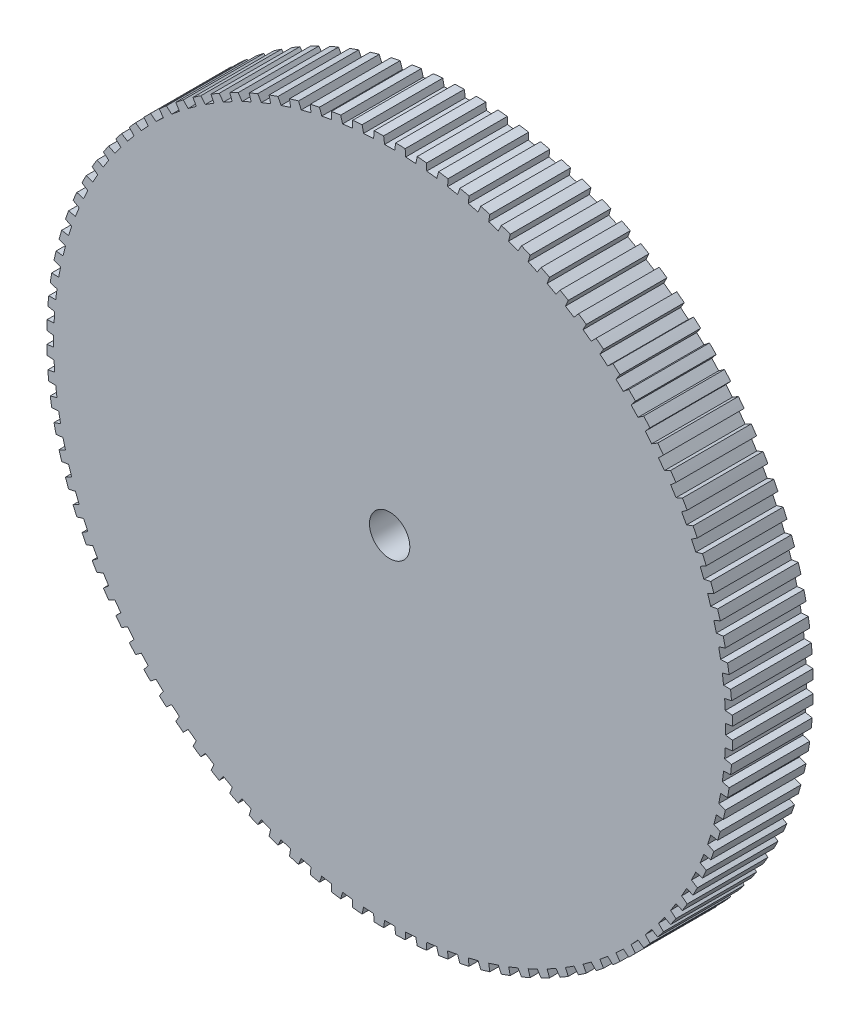
from build123d import *

# Parameters (mm, degrees)
SKETCH1_R                = 34
BOSS_EXTRUDE1_DEPTH      = 8
SKETCH4_R                = 4.85
BOSS_EXTRUDE2_DEPTH      = 8
SKETCH2_R                = 4
CUT_EXTRUDE1_DEPTH       = 4.35
SKETCH5_R                = 2
CUT_EXTRUDE2_DEPTH       = 4.15
CUT_EXTRUDE3_DEPTH       = 7.5
CUT_EXTRUDE4_DEPTH       = 17
CIRPATTERN1_COUNT        = 100
SKETCH8_R                = 4
SKETCH8_R_2              = 2
REVERSECOUNTERSINK_DEPTH = 4.35


with BuildPart() as part:
    # Sketch1 → Boss-Extrude1 (new body)
    with BuildSketch(Plane.XY):
        Circle(SKETCH1_R)
    extrude(amount=BOSS_EXTRUDE1_DEPTH)

    # Sketch4 → Boss-Extrude2 (add)
    with BuildSketch(Plane(origin=(0, 0, 0), x_dir=(-1, 0, 0), z_dir=(0, 0, -1))):
        Circle(SKETCH4_R)
    extrude(amount=BOSS_EXTRUDE2_DEPTH)

    # Sketch2 → Cut-Extrude1 (cut)
    with BuildSketch(Plane.XY.offset(8)):
        Circle(SKETCH2_R)
    extrude(amount=-CUT_EXTRUDE1_DEPTH, mode=Mode.SUBTRACT)

    # Sketch5 → Cut-Extrude2 (cut)
    with BuildSketch(Plane.XY.offset(3.65)):
        Circle(SKETCH5_R)
    extrude(amount=-CUT_EXTRUDE2_DEPTH, mode=Mode.SUBTRACT)

    # Sketch6 → Cut-Extrude3 (cut)
    with BuildSketch(Plane(origin=(0, 0, -8), x_dir=(-1, 0, 0), z_dir=(0, 0, -1))):
        with BuildLine():
            Line((2.078460969, 1.95), (-2.078460969, 1.95))
            ThreePointArc((-2.078460969, 1.95), (-2.85, 0), (-2.078460969, -1.95))
            Line((-2.078460969, -1.95), (2.078460969, -1.95))
            ThreePointArc((2.078460969, -1.95), (2.85, 0), (2.078460969, 1.95))
        make_face()
    extrude(amount=-CUT_EXTRUDE3_DEPTH, mode=Mode.SUBTRACT)

    # Sketch7 → Cut-Extrude4 (cut, through all)
    with BuildSketch(Plane.XY.offset(8)):
        with BuildLine():
            Line((-0.6, 33.99470547), (-0.5, 33.31))
            Line((-0.5, 33.31), (0.5, 33.31))
            Line((0.5, 33.31), (0.6, 33.99470547))
            ThreePointArc((0.6, 33.99470547), (0, 34), (-0.6, 33.99470547))
        make_face()
    cut_extrude4 = extrude(amount=-CUT_EXTRUDE4_DEPTH, mode=Mode.SUBTRACT)

    # CirPattern1: Cut-Extrude4 ×100 about axis
    cirpattern1_axis = Axis((0, 0, 0), (0, 0, 1))
    for i in range(1, CIRPATTERN1_COUNT):
        add(cut_extrude4.rotate(cirpattern1_axis, i * 360 / CIRPATTERN1_COUNT), mode=Mode.SUBTRACT)

    # Sketch8 → ReverseCountersink (add)
    with BuildSketch(Plane.XY.offset(3.65)):
        Circle(SKETCH8_R)
        Circle(SKETCH8_R_2, mode=Mode.SUBTRACT)
    extrude(amount=REVERSECOUNTERSINK_DEPTH)


solid = part.part
